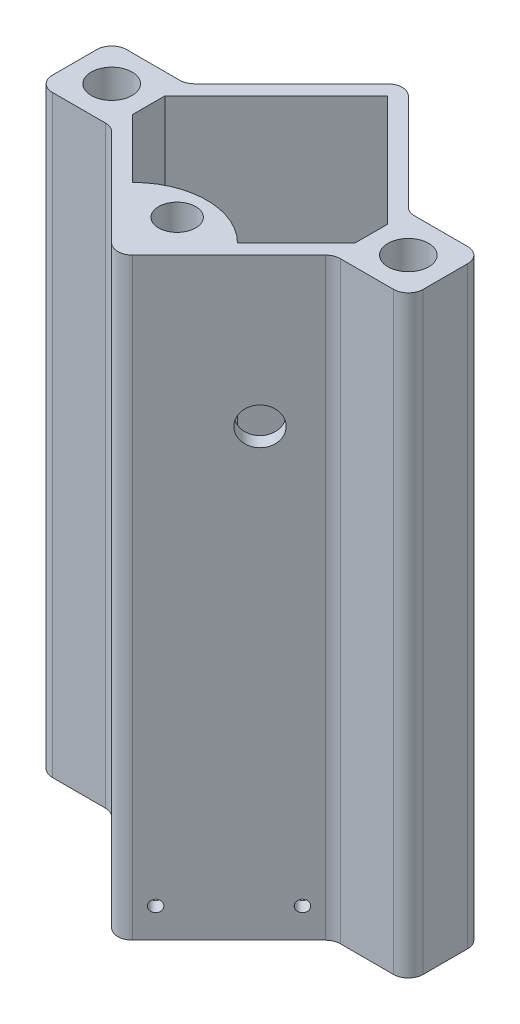
from build123d import *

# Parameters (mm, degrees)
SKETCH2_R               = 3.4925
BOSS_EXTRUDE1_DEPTH     = 101.6
FILLET1_R               = 2.54
CUT_EXTRUDE1_START      = -2.54
SKETCH11_R              = 1
CUT_EXTRUDE1_DEPTH      = 25.246691527
MIRROR3_START           = -2.54
MIRROR3_COPY_1_SKETCH_R = 1
MIRROR3_COPY_1_DEPTH    = 25.246691527
SKETCH12_R              = 3.175
CUT_EXTRUDE2_DEPTH      = 22.706691527
CUT_EXTRUDE2_DEPTH_BACK = 58.627716011
SKETCH13_R              = 3.175
CUT_EXTRUDE3_DEPTH      = 22.706691527
CUT_EXTRUDE3_DEPTH_BACK = 58.627716011
SKETCH14_R              = 3.175
BOSS_EXTRUDE2_DEPTH     = 76.2


with BuildPart() as part:
    # Sketch2 → Boss-Extrude1 (new body)
    with BuildSketch(Plane(origin=(0, 0, 0), x_dir=(1, 0, 0), z_dir=(0, 1, 0))):
        Polygon((19.05, -6.35), (31.75, -6.35), (31.75, 6.35), (19.05, 6.35), (0, 25.4), (-19.05, 6.35), (-31.75, 6.35), (-31.75, -6.35), (-19.05, -6.35), (0, -25.4), align=None)
        Polygon((-19.05, 2.757897552), (0, 21.807897552), (19.05, 2.757897552), (19.05, -2.757897552), (0, -21.807897552), (-19.05, -2.757897552), align=None, mode=Mode.SUBTRACT)
        with Locations((25.4, 0)):
            Circle(SKETCH2_R, mode=Mode.SUBTRACT)
        with Locations((-25.4, 0)):
            Circle(SKETCH2_R, mode=Mode.SUBTRACT)
    extrude(amount=BOSS_EXTRUDE1_DEPTH)

    # Fillet1
    fillet1_edges = [part.edges().sort_by_distance(p)[0] for p in [
        (0, 50.8, 25.4),
        (-19.05, 50.8, 6.35),
        (-31.75, 50.8, 6.35),
        (-31.75, 50.8, -6.35),
        (-19.05, 50.8, -6.35),
        (0, 50.8, -25.4),
        (19.05, 50.8, -6.35),
        (31.75, 50.8, -6.35),
        (31.75, 50.8, 6.35),
        (19.05, 50.8, 6.35),
    ]]
    fillet(fillet1_edges, radius=FILLET1_R)

    # Sketch11 → Cut-Extrude1 (cut)
    with BuildSketch(Plane(origin=(12.7, 0, -12.7), x_dir=(-0.707106781, 0, -0.707106781), z_dir=(0.707106781, 0, -0.707106781)).offset(CUT_EXTRUDE1_START)):
        with Locations((-5.143820715, 5.08)):
            Circle(SKETCH11_R)
        with Locations((12.636179285, 5.08)):
            Circle(SKETCH11_R)
    cut_extrude1 = extrude(amount=CUT_EXTRUDE1_DEPTH, mode=Mode.SUBTRACT)

    # Mirror2: Cut-Extrude1 across plane
    add(cut_extrude1.mirror(Plane(origin=(0, 0, 0), x_dir=(0, 0, 1), z_dir=(1, 0, 0))), mode=Mode.SUBTRACT)

    # Mirror3: Cut-Extrude1 across plane
    add(cut_extrude1.mirror(Plane.XY), mode=Mode.SUBTRACT)

    # Mirror3 copy 1 sketch → Mirror3 copy 1 (cut)
    with BuildSketch(Plane(origin=(-12.7, 0, 12.7), x_dir=(0.707106781, 0, 0.707106781), z_dir=(-0.707106781, 0, 0.707106781)).offset(MIRROR3_START)):
        with Locations((-5.143820715, 5.08)):
            Circle(MIRROR3_COPY_1_SKETCH_R)
        with Locations((12.636179285, 5.08)):
            Circle(MIRROR3_COPY_1_SKETCH_R)
    extrude(amount=MIRROR3_COPY_1_DEPTH, mode=Mode.SUBTRACT)

    # Sketch12 → Cut-Extrude2 (cut, two sides)
    with BuildSketch(Plane(origin=(-12.7, 0, -12.7), x_dir=(-0.707106781, 0, 0.707106781), z_dir=(-0.707106781, 0, -0.707106781))) as cut_extrude2_sk:
        with Locations((0, 76.2)):
            Circle(SKETCH12_R)
    extrude(amount=CUT_EXTRUDE2_DEPTH, mode=Mode.SUBTRACT)
    extrude(cut_extrude2_sk.sketch, amount=-CUT_EXTRUDE2_DEPTH_BACK, mode=Mode.SUBTRACT)

    # Sketch13 → Cut-Extrude3 (cut, two sides)
    with BuildSketch(Plane(origin=(12.7, 0, -12.7), x_dir=(-0.707106781, 0, -0.707106781), z_dir=(0.707106781, 0, -0.707106781))) as cut_extrude3_sk:
        with Locations((0, 63.5)):
            Circle(SKETCH13_R)
    extrude(amount=CUT_EXTRUDE3_DEPTH, mode=Mode.SUBTRACT)
    extrude(cut_extrude3_sk.sketch, amount=-CUT_EXTRUDE3_DEPTH_BACK, mode=Mode.SUBTRACT)

    # Sketch14 → Boss-Extrude2 (add)
    with BuildSketch(Plane(origin=(0, 101.6, 0), x_dir=(1, 0, 0), z_dir=(0, 1, 0))):
        with BuildLine():
            Line((8.980256121, -12.827641431), (0, -21.807897552))
            Line((0, -21.807897552), (-8.980256121, -12.827641431))
            ThreePointArc((-8.980256121, -12.827641431), (0, -9.107897552), (8.980256121, -12.827641431))
        make_face()
        with Locations((0, -14.187897552)):
            Circle(SKETCH14_R, mode=Mode.SUBTRACT)
    extrude(amount=-BOSS_EXTRUDE2_DEPTH)


solid = part.part
